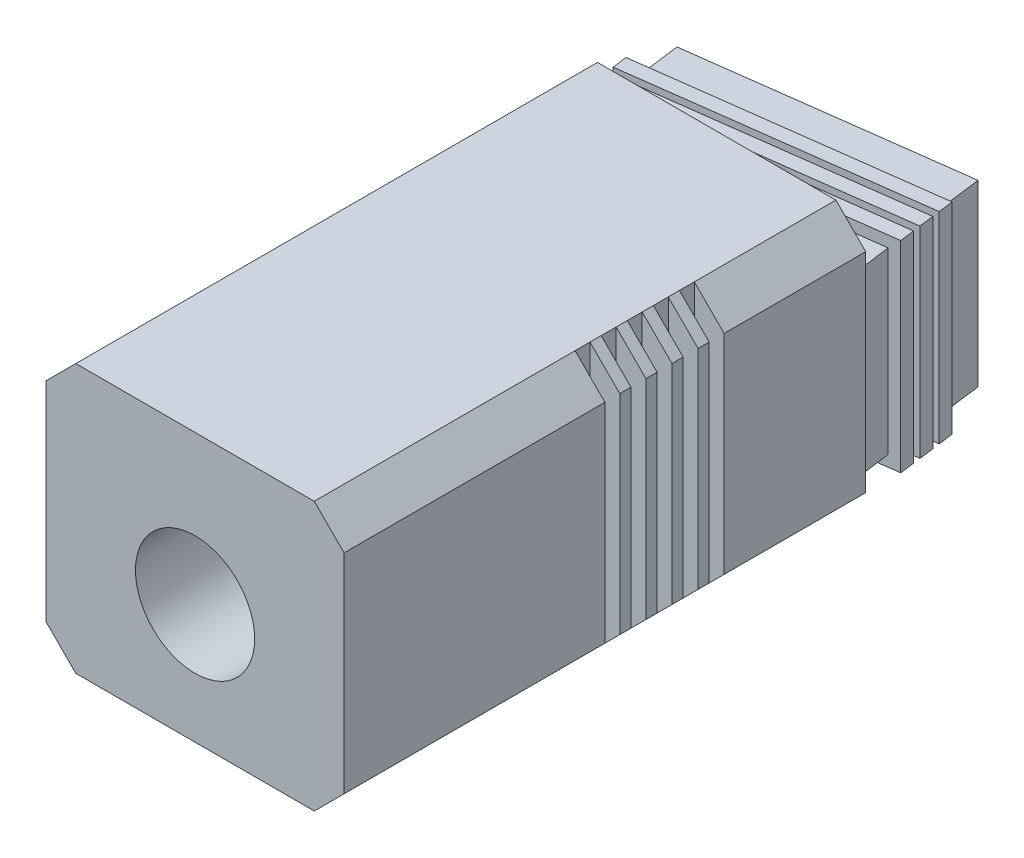
from build123d import *

# Parameters (mm, degrees)
SKETCH1_W           = 20
SKETCH1_H           = 18
BOSS_EXTRUDE1_DEPTH = 35
CHAMFER1_SIZE       = 2
SKETCH4_W           = 2
SKETCH4_H           = 1
CUT_EXTRUDE2_DEPTH  = 19
BOSS_EXTRUDE3_START = -2
BOSS_EXTRUDE3_DEPTH = 12
SKETCH2_R           = 4
CUT_EXTRUDE1_DEPTH  = 35
SKETCH8_R           = 4
SKETCH9_R           = 4
BOSS_EXTRUDE4_START = -6
SKETCH10_W          = 19.5
SKETCH10_H          = 13.5
SKETCH10_R          = 5
BOSS_EXTRUDE4_DEPTH = 1
LPATTERN1_COUNT     = 3
LPATTERN1_PITCH     = 1.5
BOSS_EXTRUDE5_DEPTH = 0.75


with BuildPart() as part:
    # Sketch1 → Boss-Extrude1 (new body)
    with BuildSketch(Plane.XY):
        Rectangle(SKETCH1_W, SKETCH1_H)
    extrude(amount=BOSS_EXTRUDE1_DEPTH)

    # Chamfer1
    chamfer1_edges = [part.edges().sort_by_distance(p)[0] for p in [
        (10, 9, 17.5),
        (10, -9, 17.5),
        (-10, -9, 17.5),
        (-10, 9, 17.5),
    ]]
    chamfer(chamfer1_edges, length=CHAMFER1_SIZE)

    # Sketch4 → Cut-Extrude2 (cut, through all)
    with BuildSketch(Plane.XZ.offset(9)):
        with Locations((-9, 10)):
            Rectangle(SKETCH4_W, SKETCH4_H)
        with Locations((-9, 11.75)):
            Rectangle(SKETCH4_W, SKETCH4_H)
        with Locations((-9, 13.5)):
            Rectangle(SKETCH4_W, SKETCH4_H)
        with Locations((-9, 15.25)):
            Rectangle(SKETCH4_W, SKETCH4_H)
        with Locations((-9, 17)):
            Rectangle(SKETCH4_W, SKETCH4_H)
        with Locations((9, 17)):
            Rectangle(SKETCH4_W, SKETCH4_H)
        with Locations((9, 15.25)):
            Rectangle(SKETCH4_W, SKETCH4_H)
        with Locations((9, 13.5)):
            Rectangle(SKETCH4_W, SKETCH4_H)
        with Locations((9, 11.75)):
            Rectangle(SKETCH4_W, SKETCH4_H)
        with Locations((9, 10)):
            Rectangle(SKETCH4_W, SKETCH4_H)
    extrude(amount=-CUT_EXTRUDE2_DEPTH, mode=Mode.SUBTRACT)

    # Sketch7 → Boss-Extrude3 (add)
    with BuildSketch(Plane.XZ.offset(9).offset(BOSS_EXTRUDE3_START)):
        Polygon((-8.923003752, 2.34947146), (8.923003752, 0), (7.61774183, -9.914448614), (-10.228265675, -7.564977154), align=None)
    extrude(amount=-BOSS_EXTRUDE3_DEPTH)

    # Sketch2 → Cut-Extrude1 (cut)
    with BuildSketch(Plane.XY.offset(35)):
        with Locations((0, -1)):
            Circle(SKETCH2_R)
    extrude(amount=-CUT_EXTRUDE1_DEPTH, mode=Mode.SUBTRACT)

    # Sketch8 → Cut-Loft1 section 0
    with BuildSketch(Plane(origin=(-1.153239932, 0, -8.759726958), x_dir=(-0.991444861, 0, 0.130526192), z_dir=(-0.130526192, 0, -0.991444861))):
        with Locations((0, -1)):
            Circle(SKETCH8_R)
    # Sketch9 → Cut-Loft1 section 1
    with BuildSketch(Plane.XY):
        with Locations((0, -1)):
            Circle(SKETCH9_R)
    loft(mode=Mode.SUBTRACT)

    # Sketch10 → Boss-Extrude4 (add)
    with BuildSketch(Plane(origin=(-1.153239932, 0, -8.759726958), x_dir=(-0.991444861, 0, 0.130526192), z_dir=(-0.130526192, 0, -0.991444861)).offset(BOSS_EXTRUDE4_START)):
        with Locations((0.153333782, -1)):
            Rectangle(SKETCH10_W, SKETCH10_H)
        with Locations((0, -1)):
            Circle(SKETCH10_R, mode=Mode.SUBTRACT)
    boss_extrude4 = extrude(amount=-BOSS_EXTRUDE4_DEPTH)

    # LPattern1: Boss-Extrude4 ×3
    with Locations(*[Vector(-0.130526192, 0, -0.991444861) * (i * LPATTERN1_PITCH) for i in range(1, LPATTERN1_COUNT)]):
        add(boss_extrude4)

    # Sketch11 → Boss-Extrude5 (add)
    with BuildSketch(Plane.XZ.offset(7)):
        Polygon((-9.706160906, -3.599197708), (8.139846599, -5.948669168), (8.400898983, -3.965779445), (-9.445108521, -1.616307986), align=None)
    extrude(amount=BOSS_EXTRUDE5_DEPTH)


solid = part.part
